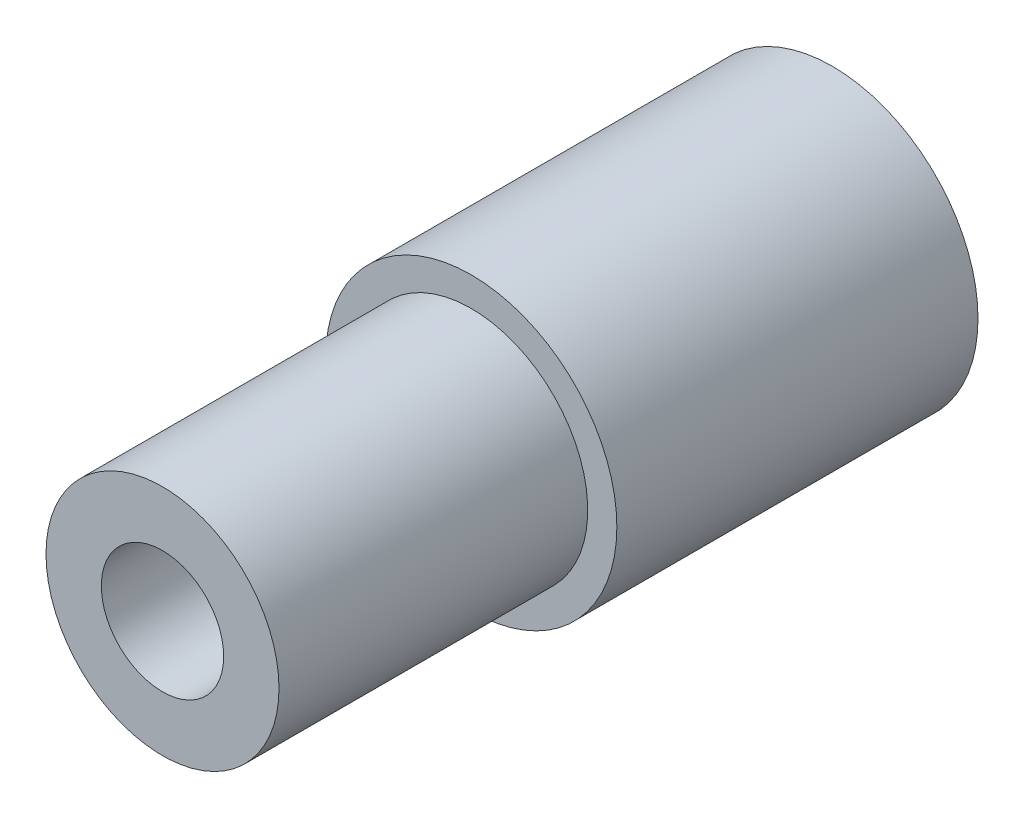
from build123d import *

# Parameters (mm, degrees)
SKETCH2_R           = 4
SKETCH2_R_2         = 2.1
BOSS_EXTRUDE1_DEPTH = 23
SKETCH3_R           = 5
SKETCH3_R_2         = 4
BOSS_EXTRUDE2_DEPTH = 12.4


with BuildPart() as part:
    # Sketch2 → Boss-Extrude1 (new body)
    with BuildSketch(Plane.XY):
        Circle(SKETCH2_R)
        Circle(SKETCH2_R_2, mode=Mode.SUBTRACT)
    extrude(amount=BOSS_EXTRUDE1_DEPTH)

    # Sketch3 → Boss-Extrude2 (add)
    with BuildSketch(Plane(origin=(0, 0, 0), x_dir=(-1, 0, 0), z_dir=(0, 0, -1))):
        Circle(SKETCH3_R)
        Circle(SKETCH3_R_2, mode=Mode.SUBTRACT)
    extrude(amount=-BOSS_EXTRUDE2_DEPTH)


solid = part.part
